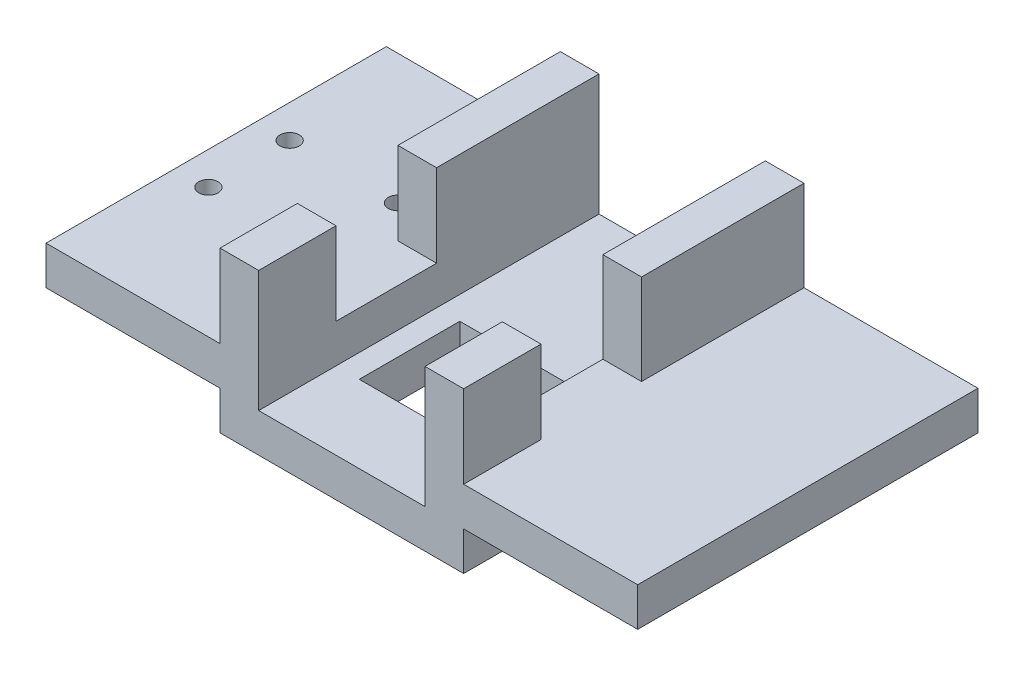
from build123d import *

# Parameters (mm, degrees)
BOSS_EXTRUDE1_DEPTH = 42
BOSS_EXTRUDE2_DEPTH = 46
SKETCH3_W           = 20
SKETCH3_H           = 10
BOSS_EXTRUDE3_DEPTH = 31
SKETCH4_W           = 10
SKETCH4_H           = 20
BOSS_EXTRUDE4_DEPTH = 21.387158
SKETCH6_R           = 2.5
CUT_EXTRUDE1_DEPTH  = 21


with BuildPart() as part:
    # Sketch1 → Boss-Extrude1 (new body)
    with BuildSketch(Plane.XY):
        Polygon((0, -4.144365492), (10, -4.144365492), (10, -35.531523796), (53, -35.531523796), (53, -2.113321439), (63, -2.113321439), (63, -25.531523796), (108, -25.531523796), (108, -35.531523796), (63, -35.531523796), (63, -45.531523796), (0, -45.531523796), (0, -35.531523796), (-45, -35.531523796), (-45, -25.531523796), (0, -25.531523796), align=None)
    extrude(amount=BOSS_EXTRUDE1_DEPTH)

    # Sketch2 → Boss-Extrude2 (add)
    with BuildSketch(Plane.XY.offset(42)):
        Polygon((-45, -25.531523796), (10, -25.531523796), (10, -35.531523796), (16, -35.531523796), (16, -45.531523796), (0, -45.531523796), (0, -35.531523796), (-45, -35.531523796), align=None)
        Polygon((53, -25.531523796), (108, -25.531523796), (108, -35.531523796), (63, -35.531523796), (63, -45.531523796), (47, -45.531523796), (47, -35.531523796), (53, -35.531523796), align=None)
    extrude(amount=BOSS_EXTRUDE2_DEPTH)

    # Sketch3 → Boss-Extrude3 (add)
    with BuildSketch(Plane.ZY.offset(-47)):
        with Locations((78, -40.531523796)):
            Rectangle(SKETCH3_W, SKETCH3_H)
    extrude(amount=BOSS_EXTRUDE3_DEPTH)

    # Sketch4 → Boss-Extrude4 (add)
    with BuildSketch(Plane(origin=(0, -25.531523796, 0), x_dir=(1, 0, 0), z_dir=(0, 1, 0))):
        with Locations((5, -78)):
            Rectangle(SKETCH4_W, SKETCH4_H)
        with Locations((58, -78)):
            Rectangle(SKETCH4_W, SKETCH4_H)
    extrude(amount=BOSS_EXTRUDE4_DEPTH)

    # Sketch6 → Cut-Extrude1 (cut, through all)
    with BuildSketch(Plane(origin=(0, -25.531523796, 0), x_dir=(1, 0, 0), z_dir=(0, 1, 0))):
        with Locations((-36.5, -54.5)):
            Circle(SKETCH6_R)
        with Locations((-8.5, -54.5)):
            Circle(SKETCH6_R)
        with Locations((-36.5, -33.5)):
            Circle(SKETCH6_R)
        with Locations((-8.5, -33.5)):
            Circle(SKETCH6_R)
    extrude(amount=-CUT_EXTRUDE1_DEPTH, mode=Mode.SUBTRACT)


solid = part.part
